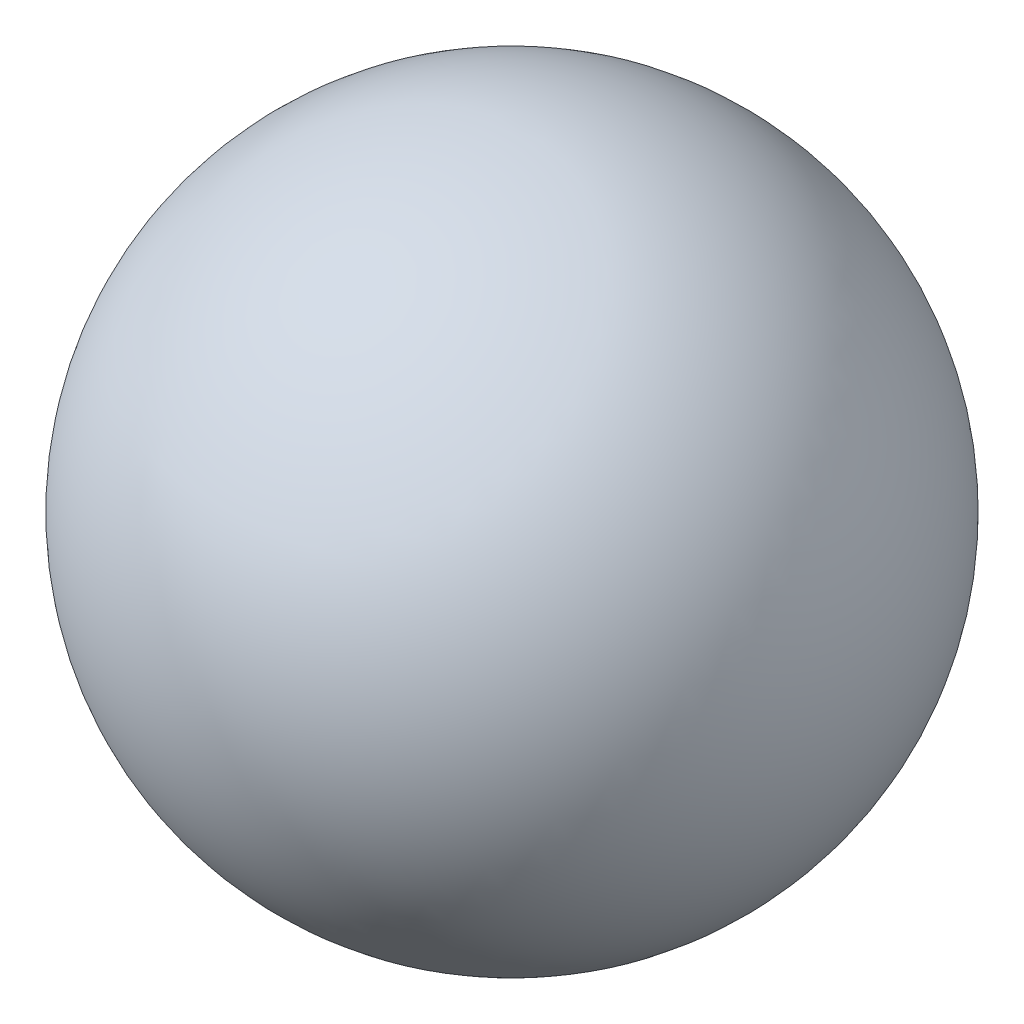
from build123d import *


with BuildPart() as part:
    # Sketch1 → Revolve1 (revolve)
    with BuildSketch(Plane.XY):
        with BuildLine():
            Line((0, -65), (0, 65))
            ThreePointArc((0, 65), (-65, 0), (0, -65))
        make_face()
    revolve(axis=Axis((0, -65, 0), (0, 1, 0)))


solid = part.part
